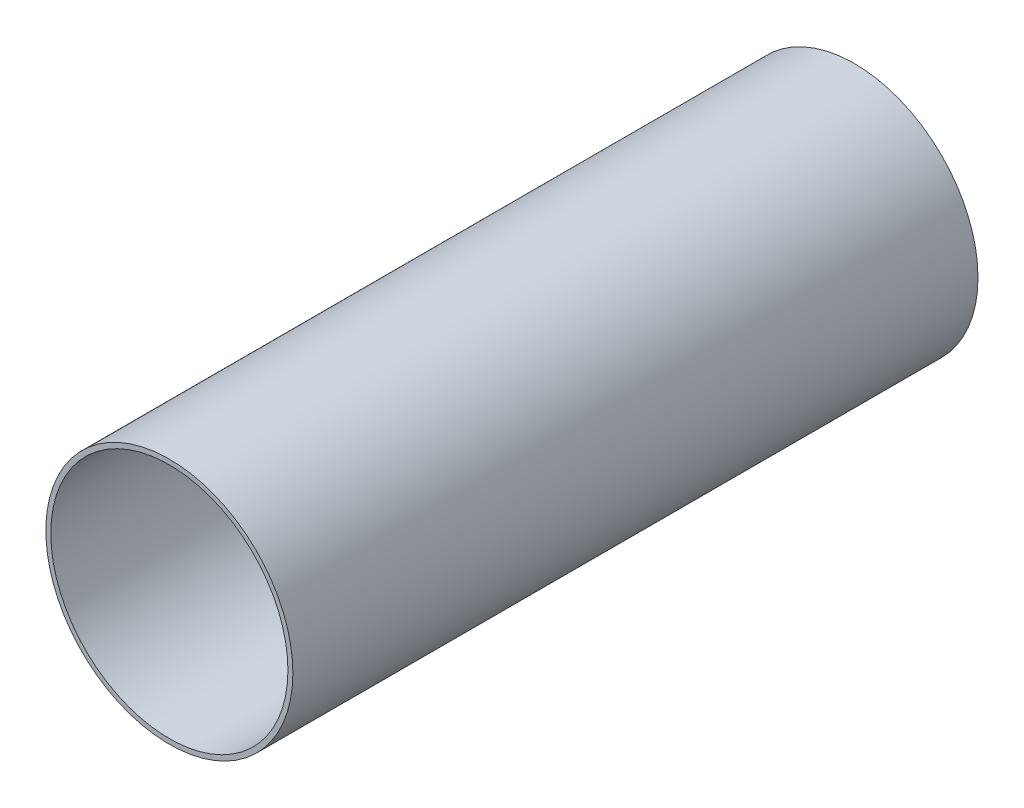
from build123d import *

# Parameters (mm, degrees)
SKETCH1_R           = 39.6875
SKETCH1_R_2         = 38.1
BOSS_EXTRUDE1_DEPTH = 220.1418


with BuildPart() as part:
    # Sketch1 → Boss-Extrude1 (new body)
    with BuildSketch(Plane.XY):
        Circle(SKETCH1_R)
        Circle(SKETCH1_R_2, mode=Mode.SUBTRACT)
    extrude(amount=BOSS_EXTRUDE1_DEPTH)


solid = part.part
